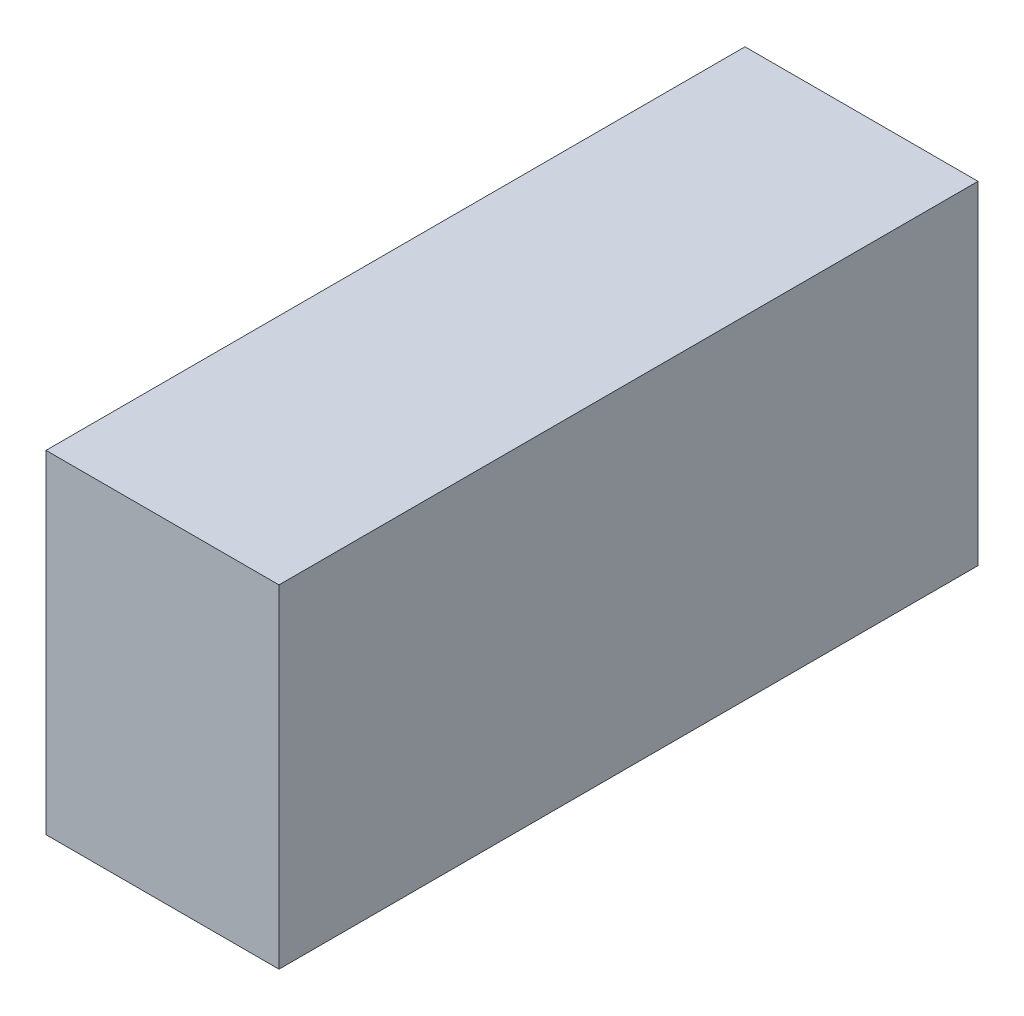
from build123d import *

# Parameters (mm, degrees)
SKETCH2_W           = 22.225
SKETCH2_H           = 66.675
BOSS_EXTRUDE1_DEPTH = 31.75


with BuildPart() as part:
    # Sketch2 → Boss-Extrude1 (new body)
    with BuildSketch(Plane(origin=(0, 0, 0), x_dir=(1, 0, 0), z_dir=(0, 1, 0))):
        with Locations((11.1125, 33.3375)):
            Rectangle(SKETCH2_W, SKETCH2_H)
    extrude(amount=BOSS_EXTRUDE1_DEPTH)


solid = part.part
